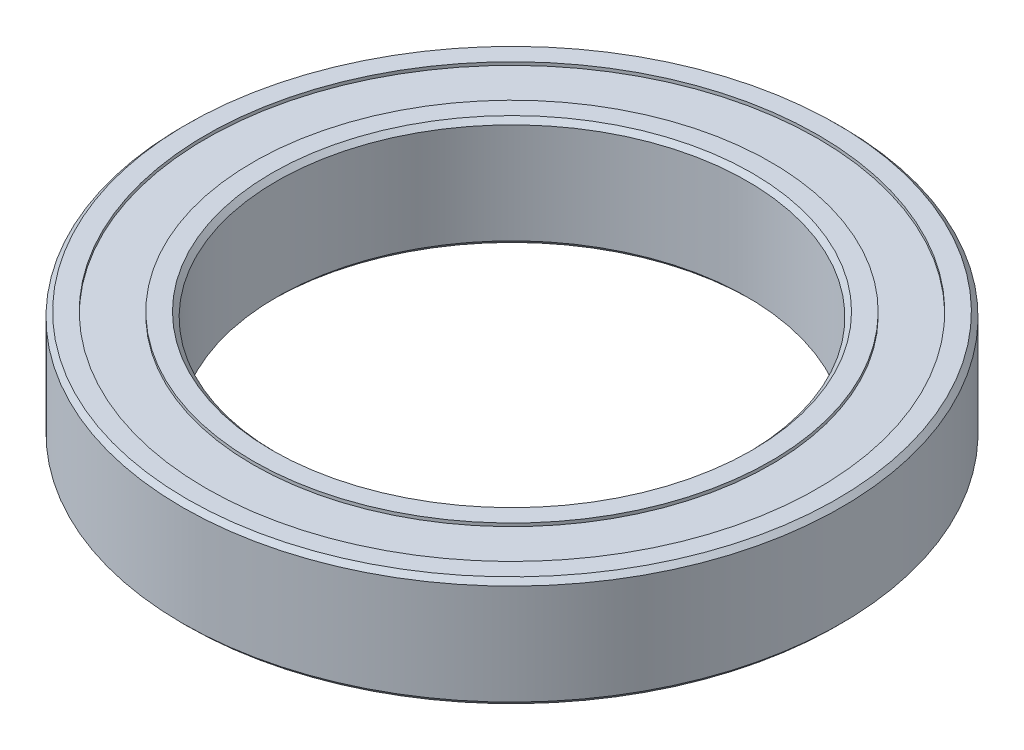
from build123d import *

# Parameters (mm, degrees)
SKETCH1_R           = 21
SKETCH1_R_2         = 15
BOSS_EXTRUDE1_DEPTH = 7
SKETCH2_R           = 19.5
SKETCH2_R_2         = 16.5
CUT_EXTRUDE1_DEPTH  = 0.2
CHAMFER1_SIZE       = 0.3
SKETCH3_R           = 19.5
SKETCH3_R_2         = 16.5
CUT_EXTRUDE2_DEPTH  = 0.2


with BuildPart() as part:
    # Sketch1 → Boss-Extrude1 (new body)
    with BuildSketch(Plane(origin=(0, 0, 0), x_dir=(1, 0, 0), z_dir=(0, 1, 0))):
        Circle(SKETCH1_R)
        Circle(SKETCH1_R_2, mode=Mode.SUBTRACT)
    extrude(amount=BOSS_EXTRUDE1_DEPTH)

    # Sketch2 → Cut-Extrude1 (cut)
    with BuildSketch(Plane(origin=(0, 7, 0), x_dir=(1, 0, 0), z_dir=(0, 1, 0))):
        Circle(SKETCH2_R)
        Circle(SKETCH2_R_2, mode=Mode.SUBTRACT)
    extrude(amount=-CUT_EXTRUDE1_DEPTH, mode=Mode.SUBTRACT)

    # Chamfer1
    chamfer1_edges = [part.edges().sort_by_distance(p)[0] for p in [
        (-21, 0, 0),
        (-21, 7, 0),
        (-15, 0, 0),
        (-15, 7, 0),
    ]]
    chamfer(chamfer1_edges, length=CHAMFER1_SIZE)

    # Sketch3 → Cut-Extrude2 (cut)
    with BuildSketch(Plane.XZ):
        Circle(SKETCH3_R)
        Circle(SKETCH3_R_2, mode=Mode.SUBTRACT)
    extrude(amount=-CUT_EXTRUDE2_DEPTH, mode=Mode.SUBTRACT)


solid = part.part
